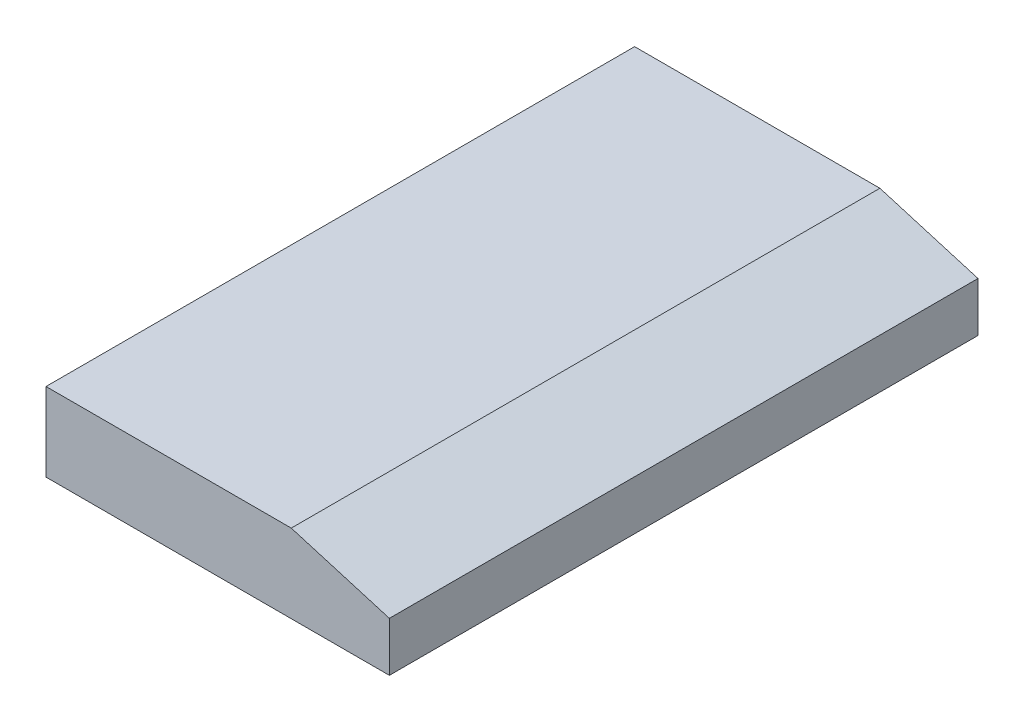
from build123d import *

# Parameters (mm, degrees)
SALIENTE_EXTRUIR1_DEPTH = 600


with BuildPart() as part:
    # Croquis1 → Saliente-Extruir1 (new body)
    with BuildSketch(Plane.XY):
        Polygon((-175, -40), (175, -40), (175, 10.348416548), (75, 40), (-175, 40), align=None)
    extrude(amount=SALIENTE_EXTRUIR1_DEPTH)


solid = part.part
